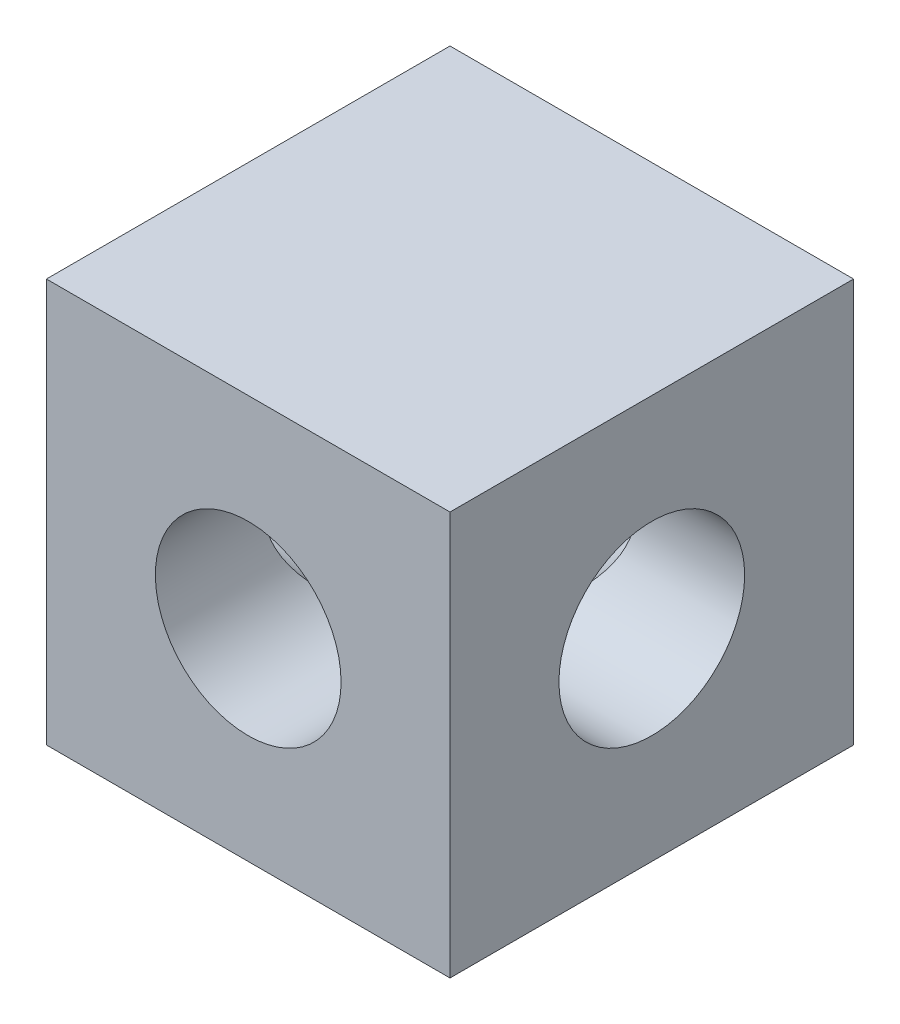
from build123d import *

# Parameters (mm, degrees)
SKETCH1_W                      = 20.32
SKETCH1_H                      = 20.32
SKETCH1_R                      = 4.675
BOSS_EXTRUDE1_DEPTH            = 20.32
F_20_0_20_DIAMETER_HOLE1_D     = 9.35
F_20_0_20_DIAMETER_HOLE1_DEPTH = 20.32
F_20_0_20_DIAMETER_HOLE1_TIP   = 2.809023394


with BuildPart() as part:
    # Sketch1 → Boss-Extrude1 (new body)
    with BuildSketch(Plane.XY):
        Rectangle(SKETCH1_W, SKETCH1_H)
        Circle(SKETCH1_R, mode=Mode.SUBTRACT)
    extrude(amount=BOSS_EXTRUDE1_DEPTH)

    # Ø20.0 (20) Diameter Hole1
    with Locations(Plane(origin=(10.16, 0, 0), x_dir=(0, 0, -1), z_dir=(1, 0, 0))):
        with Locations((-10.16, 0)):
            Hole(F_20_0_20_DIAMETER_HOLE1_D / 2, depth=F_20_0_20_DIAMETER_HOLE1_DEPTH)
            with Locations((0, 0, -(F_20_0_20_DIAMETER_HOLE1_DEPTH + F_20_0_20_DIAMETER_HOLE1_TIP / 2))):  # 118° drill point
                Cone(0, F_20_0_20_DIAMETER_HOLE1_D / 2, F_20_0_20_DIAMETER_HOLE1_TIP, mode=Mode.SUBTRACT)


solid = part.part
